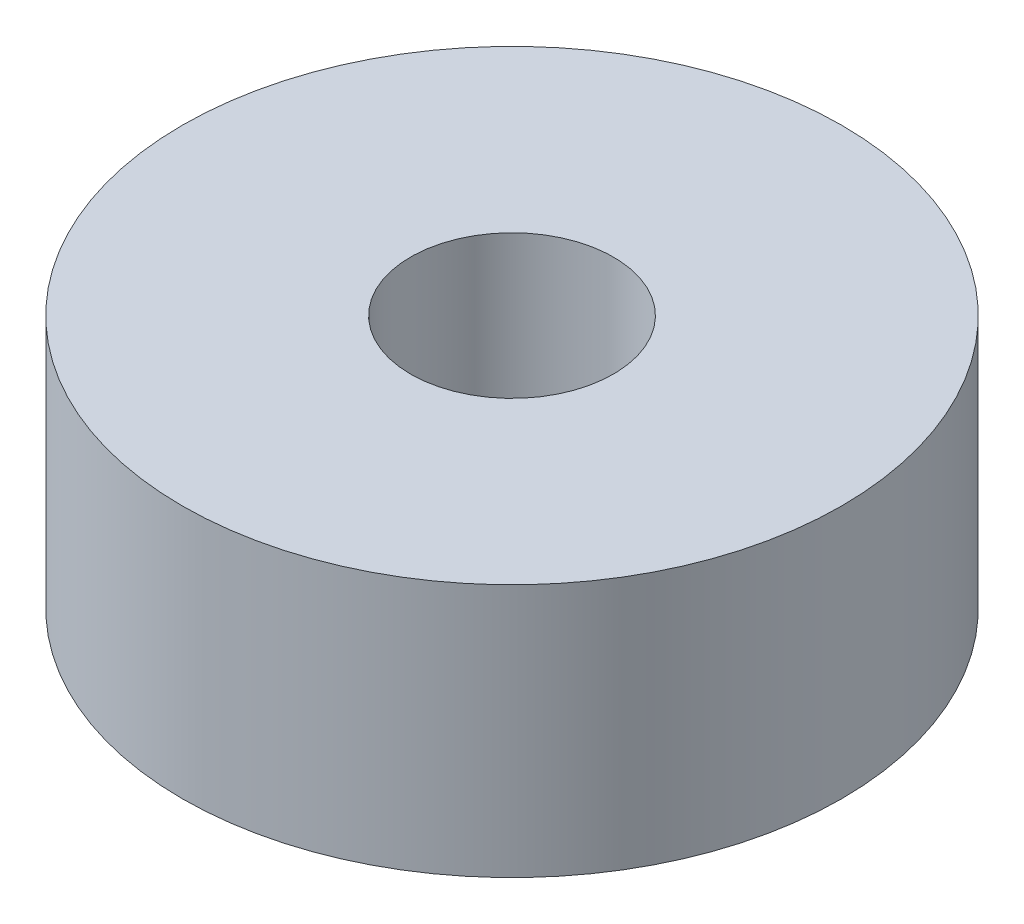
from build123d import *

# Parameters (mm, degrees)
SKETCH_1_R      = 6.5
SKETCH_1_R_2    = 2
EXTRUDE_1_DEPTH = 5


with BuildPart() as part:
    # 草图1 → 凸台-拉伸1 (new body)
    with BuildSketch(Plane(origin=(0, 0, 0), x_dir=(1, 0, 0), z_dir=(0, 1, 0))):
        Circle(SKETCH_1_R)
        Circle(SKETCH_1_R_2, mode=Mode.SUBTRACT)
    extrude(amount=EXTRUDE_1_DEPTH)


solid = part.part
